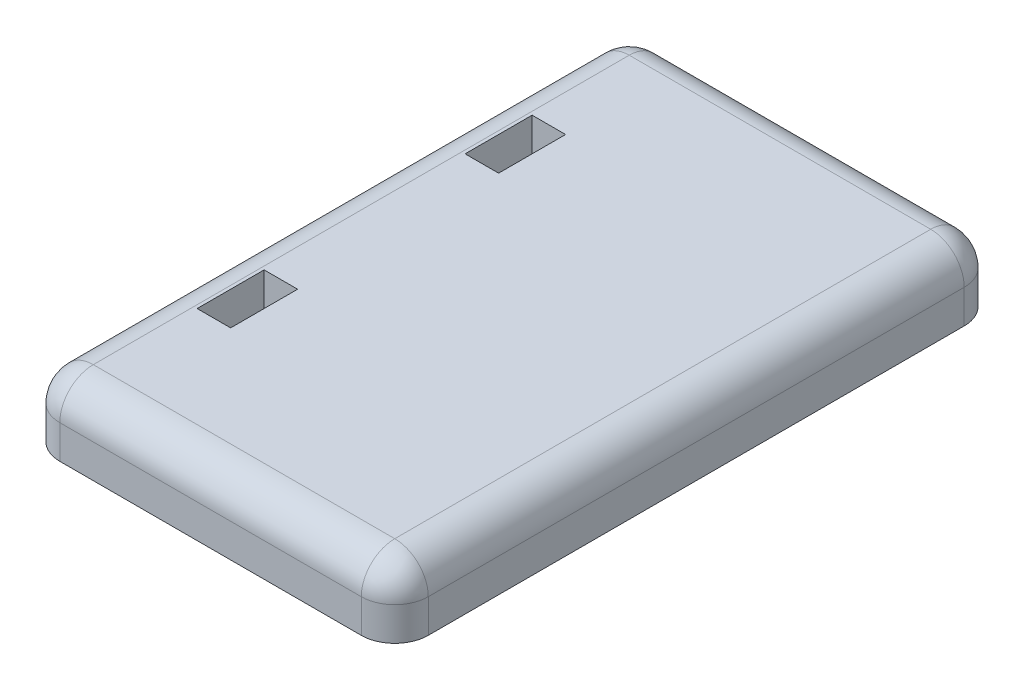
from build123d import *

# Parameters (mm, degrees)
SKETCH_2_W          = 55
SKETCH_2_H          = 90
EXTRUDE_1_DEPTH     = 10
FILLET_1_R          = 5
FILLET_2_R          = 5
FILLET_3_R          = 5
FILLET_4_R          = 5
SKETCH_3_W          = 5
SKETCH_3_H          = 10
CUT_EXTRUDE_1_DEPTH = 5


with BuildPart() as part:
    # 草图2 → 凸台-拉伸1 (new body)
    with BuildSketch(Plane(origin=(0, 0, 0), x_dir=(1, 0, 0), z_dir=(0, 1, 0))):
        Rectangle(SKETCH_2_W, SKETCH_2_H)
    extrude(amount=EXTRUDE_1_DEPTH)

    # 圆角1
    fillet_1_edges = [part.edges().sort_by_distance(p)[0] for p in [
        (-27.5, 10, 0),
    ]]
    fillet(fillet_1_edges, radius=FILLET_1_R)

    # 圆角2
    fillet_2_edges = [part.edges().sort_by_distance(p)[0] for p in [
        (-27.5, 2.5, -45),
        (-26.035533906, 8.535533906, -45),
        (2.5, 10, -45),
    ]]
    fillet(fillet_2_edges, radius=FILLET_2_R)

    # 圆角3
    fillet_3_edges = [part.edges().sort_by_distance(p)[0] for p in [
        (27.5, 2.5, -45),
        (27.5, 8.535533906, -43.535533906),
        (27.5, 10, 2.5),
    ]]
    fillet(fillet_3_edges, radius=FILLET_3_R)

    # 圆角4
    fillet_4_edges = [part.edges().sort_by_distance(p)[0] for p in [
        (0, 10, 45),
        (-27.5, 2.5, 45),
        (-26.035533906, 8.535533906, 45),
        (27.5, 2.5, 45),
        (26.035533906, 8.535533906, 45),
    ]]
    fillet(fillet_4_edges, radius=FILLET_4_R)

    # 草图3 → 切除-拉伸1 (cut)
    with BuildSketch(Plane(origin=(0, 10, 0), x_dir=(1, 0, 0), z_dir=(0, 1, 0))):
        with Locations((-19.5, 20)):
            Rectangle(SKETCH_3_W, SKETCH_3_H)
        with Locations((-19.5, -20)):
            Rectangle(SKETCH_3_W, SKETCH_3_H)
    extrude(amount=-CUT_EXTRUDE_1_DEPTH, mode=Mode.SUBTRACT)


solid = part.part
